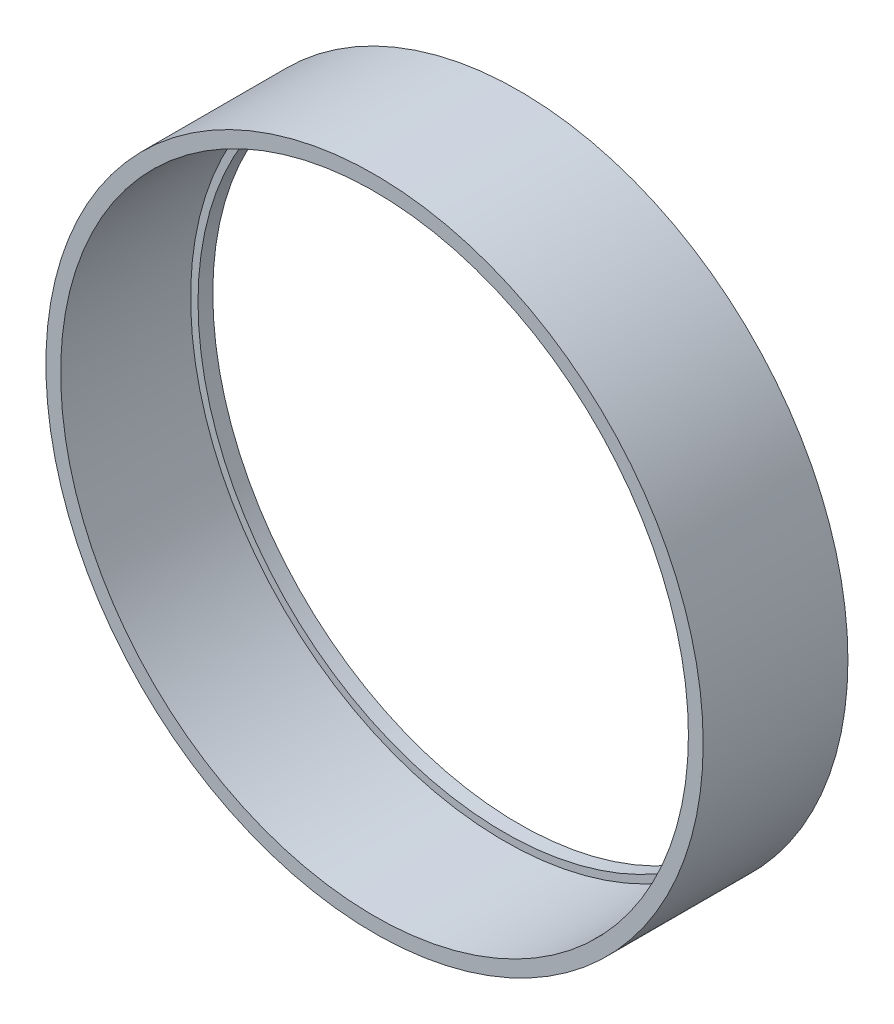
from build123d import *

# Parameters (mm, degrees)
SKETCH1_R           = 22.25
SKETCH1_R_2         = 21.25
BOSS_EXTRUDE1_DEPTH = 9.8
SKETCH1_3_R         = 21.25
SKETCH1_3_R_2       = 20.75
BOSS_EXTRUDE2_DEPTH = 1


with BuildPart() as part:
    # Sketch1 → Boss-Extrude1 (new body)
    with BuildSketch(Plane.XY):
        Circle(SKETCH1_R)
        Circle(SKETCH1_R_2, mode=Mode.SUBTRACT)
    extrude(amount=BOSS_EXTRUDE1_DEPTH)

    # Sketch1_3 → Boss-Extrude2 (add)
    with BuildSketch(Plane.XY):
        Circle(SKETCH1_3_R)
        Circle(SKETCH1_3_R_2, mode=Mode.SUBTRACT)
    extrude(amount=BOSS_EXTRUDE2_DEPTH)


solid = part.part
